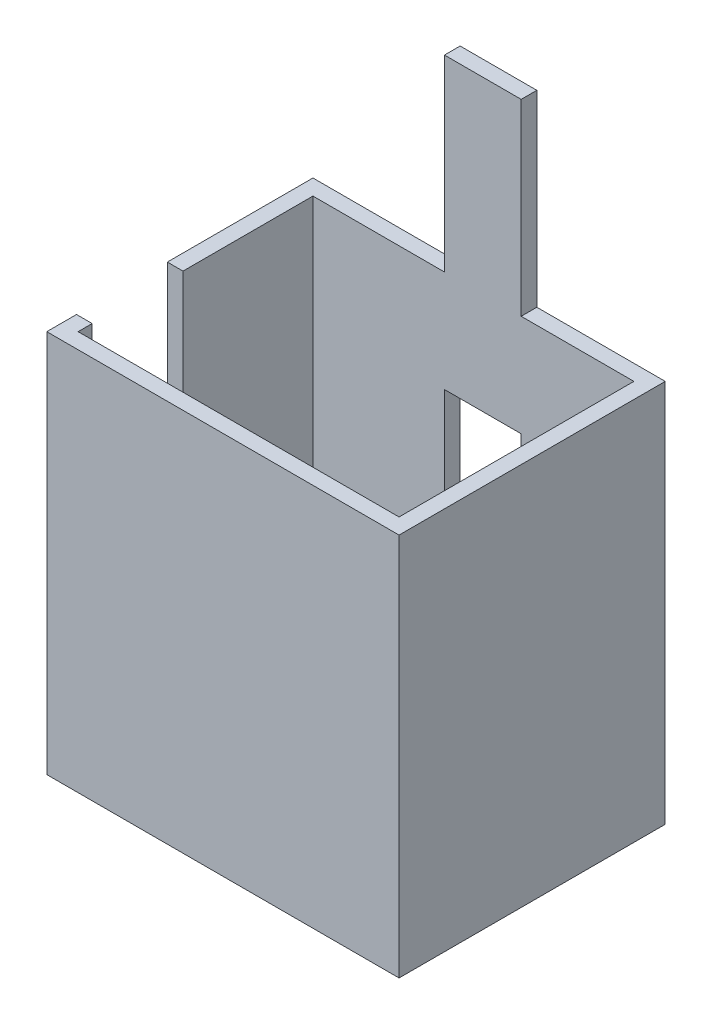
from build123d import *

# Parameters (mm, degrees)
SKETCH1_W           = 300
SKETCH1_H           = 50
SKETCH1_W_2         = 490
SKETCH1_H_2         = 100
BOSS_EXTRUDE2_DEPTH = 2450
BOSS_EXTRUDE3_START = 1200
SKETCH1_5_W         = 490
SKETCH1_5_H         = 100
BOSS_EXTRUDE3_DEPTH = 2450
SKETCH1_6_W         = 490
SKETCH1_6_H         = 100
CUT_EXTRUDE1_DEPTH  = 1800


with BuildPart() as part:
    # Sketch1 → Boss-Extrude2 (new body)
    with BuildSketch(Plane(origin=(0, 0, 0), x_dir=(1, 0, 0), z_dir=(0, 1, 0))):
        Polygon((780, 1500), (840, 1500), (840, 1600), (-100, 1600), (-100, 670), (0, 670), (0, 1030), (0, 1500), align=None)
        Polygon((1330, 1500), (1360, 1500), (2050, 1500), (2050, 0), (1360, 0), (1160, 0), (1160, -50), (860, -50), (560, -50), (560, 0), (0, 0), (0, 90), (-100, 90), (-100, -100), (2150, -100), (2150, 1600), (1330, 1600), align=None)
        with Locations((1010, -25)):
            Rectangle(SKETCH1_W, SKETCH1_H)
        with Locations((710, -25)):
            Rectangle(SKETCH1_W, SKETCH1_H)
        with Locations((1085, 1550)):
            Rectangle(SKETCH1_W_2, SKETCH1_H_2)
    extrude(amount=BOSS_EXTRUDE2_DEPTH)

    # Sketch1_5 → Boss-Extrude3 (add)
    with BuildSketch(Plane(origin=(0, 0, 0), x_dir=(1, 0, 0), z_dir=(0, 1, 0)).offset(BOSS_EXTRUDE3_START)):
        with Locations((1085, 1550)):
            Rectangle(SKETCH1_5_W, SKETCH1_5_H)
    extrude(amount=BOSS_EXTRUDE3_DEPTH)

    # Sketch1_6 → Cut-Extrude1 (cut)
    with BuildSketch(Plane(origin=(0, 0, 0), x_dir=(1, 0, 0), z_dir=(0, 1, 0))):
        with Locations((1085, 1550)):
            Rectangle(SKETCH1_6_W, SKETCH1_6_H)
    extrude(amount=CUT_EXTRUDE1_DEPTH, mode=Mode.SUBTRACT)


solid = part.part
